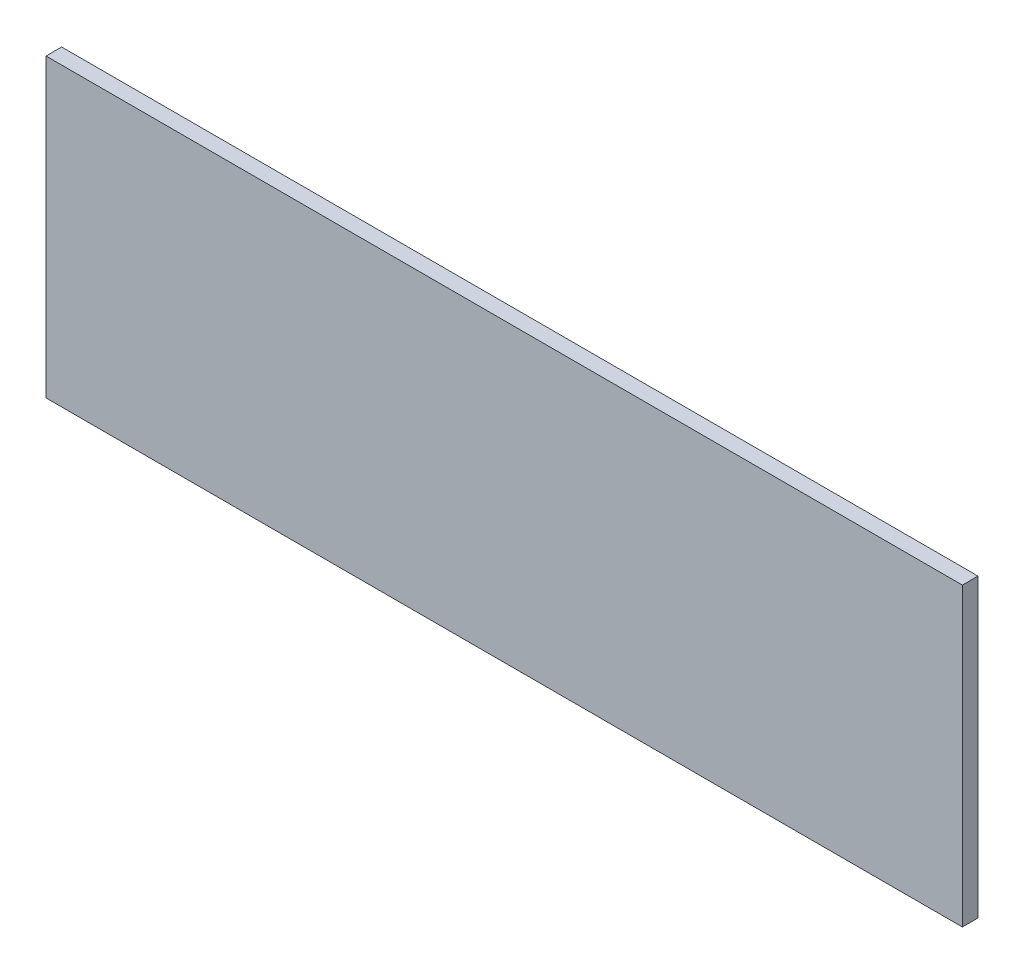
from build123d import *

# Parameters (mm, degrees)
SKETCH1_W           = 44.704
SKETCH1_H           = 14.44625
BOSS_EXTRUDE1_DEPTH = 0.762


with BuildPart() as part:
    # Sketch1 → Boss-Extrude1 (new body)
    with BuildSketch(Plane.XY):
        with Locations((39.37, -165.5922297)):
            Rectangle(SKETCH1_W, SKETCH1_H)
    extrude(amount=BOSS_EXTRUDE1_DEPTH)


solid = part.part
